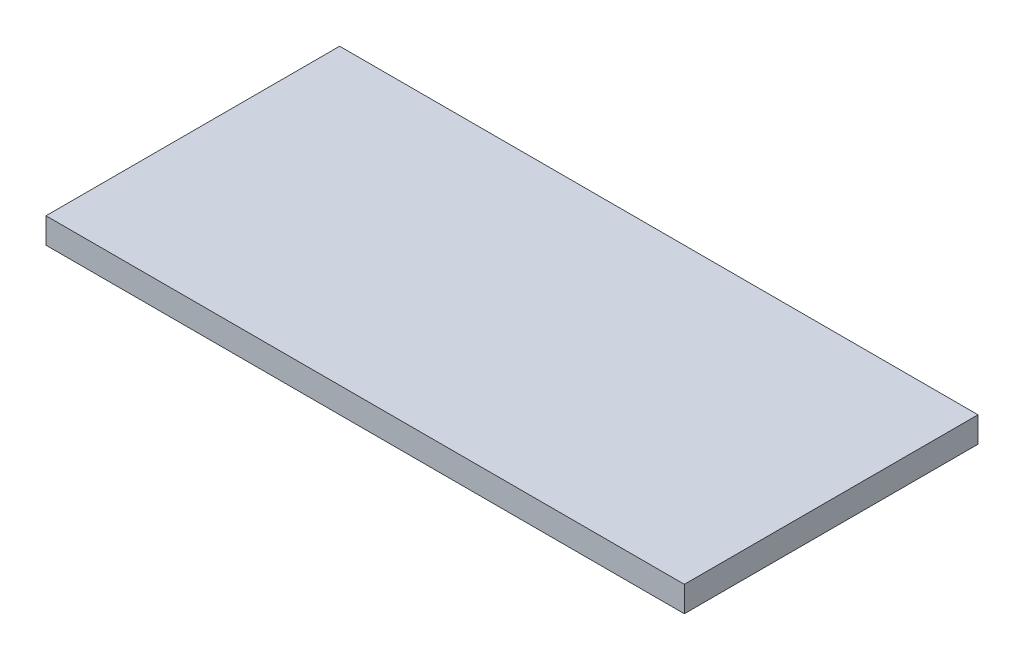
from build123d import *

# Parameters (mm, degrees)
SKETCH1_W           = 150
SKETCH1_H           = 69
BOSS_EXTRUDE1_DEPTH = 6


with BuildPart() as part:
    # Sketch1 → Boss-Extrude1 (new body)
    with BuildSketch(Plane(origin=(0, 0, 0), x_dir=(1, 0, 0), z_dir=(0, 1, 0))):
        Rectangle(SKETCH1_W, SKETCH1_H)
    extrude(amount=BOSS_EXTRUDE1_DEPTH)


solid = part.part
